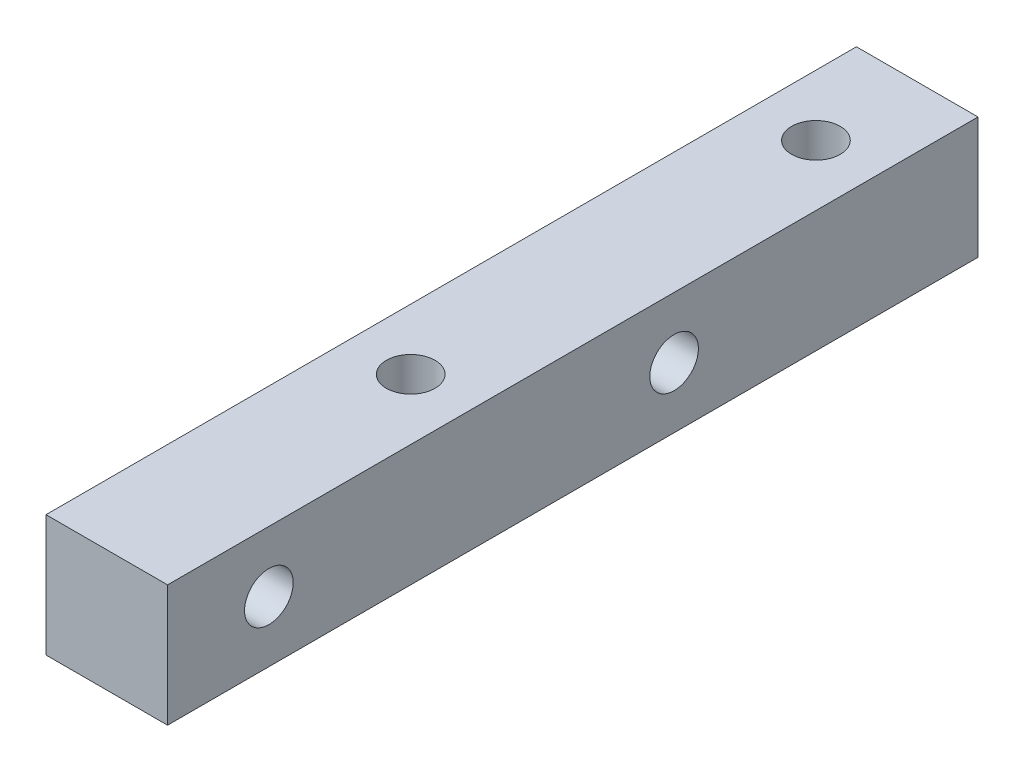
from build123d import *

# Parameters (mm, degrees)
SKETCH_1_W          = 6
SKETCH_1_H          = 6
EXTRUDE_1_DEPTH     = 40
SKETCH_2_R          = 1.2
CUT_EXTRUDE_1_DEPTH = 50
SKETCH_3_R          = 1.2
CUT_EXTRUDE_2_DEPTH = 50


with BuildPart() as part:
    # 草图1 → 凸台-拉伸1 (new body)
    with BuildSketch(Plane.XY):
        with Locations((3, 3)):
            Rectangle(SKETCH_1_W, SKETCH_1_H)
    extrude(amount=EXTRUDE_1_DEPTH)

    # 草图2 → 切除-拉伸1 (cut)
    with BuildSketch(Plane(origin=(0, 6, 0), x_dir=(1, 0, 0), z_dir=(0, 1, 0))):
        with Locations((3, -5)):
            Circle(SKETCH_2_R)
        with Locations((3, -25)):
            Circle(SKETCH_2_R)
    extrude(amount=-CUT_EXTRUDE_1_DEPTH, mode=Mode.SUBTRACT)

    # 草图3 → 切除-拉伸2 (cut)
    with BuildSketch(Plane.ZY):
        with Locations((35, 3)):
            Circle(SKETCH_3_R)
        with Locations((15, 3)):
            Circle(SKETCH_3_R)
    extrude(amount=-CUT_EXTRUDE_2_DEPTH, mode=Mode.SUBTRACT)


solid = part.part
